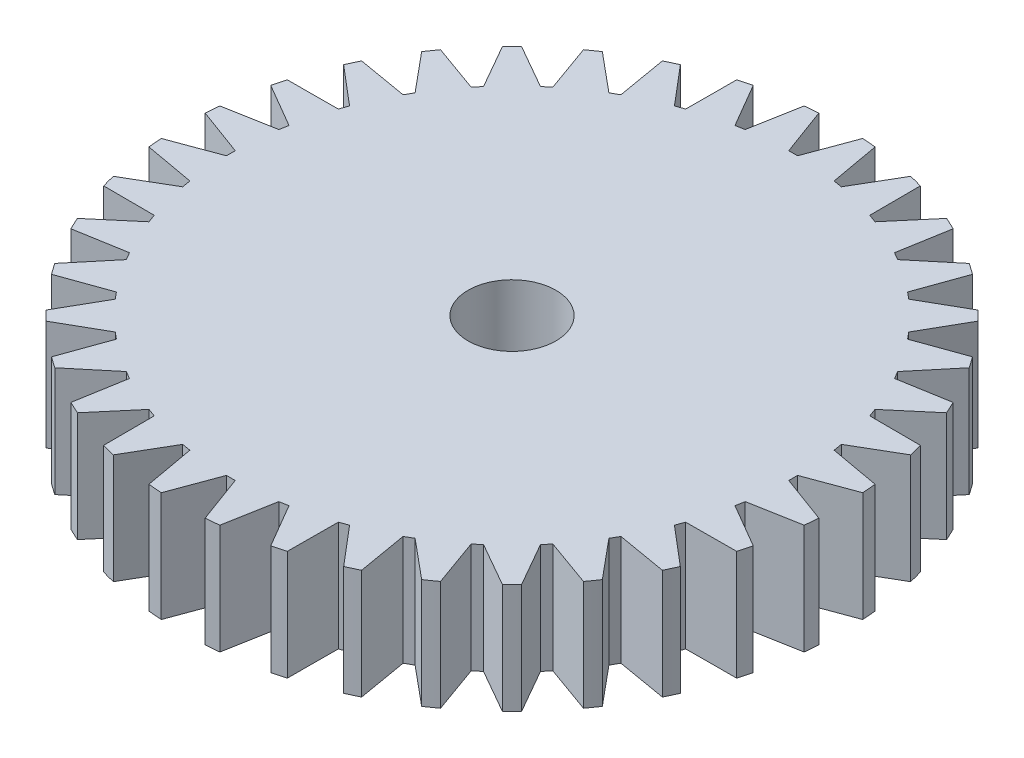
from build123d import *

# Parameters (mm, degrees)
SKETCH1_R           = 15
BOSS_EXTRUDE1_DEPTH = 5
SKETCH2_R           = 2
CUT_EXTRUDE1_DEPTH  = 6
CUT_EXTRUDE2_DEPTH  = 10
CIRPATTERN1_COUNT   = 36


with BuildPart() as part:
    # Sketch1 → Boss-Extrude1 (new body)
    with BuildSketch(Plane(origin=(0, 0, 0), x_dir=(1, 0, 0), z_dir=(0, 1, 0))):
        Circle(SKETCH1_R)
    extrude(amount=BOSS_EXTRUDE1_DEPTH)

    # Sketch2 → Cut-Extrude1 (cut, through all)
    with BuildSketch(Plane(origin=(0, 5, 0), x_dir=(1, 0, 0), z_dir=(0, 1, 0))):
        Circle(SKETCH2_R)
    extrude(amount=-CUT_EXTRUDE1_DEPTH, mode=Mode.SUBTRACT)

    # Sketch3 → Cut-Extrude2 (cut)
    with BuildSketch(Plane(origin=(0, 5, 0), x_dir=(1, 0, 0), z_dir=(0, 1, 0))):
        Polygon((0, 12.8), (0.2, 12.8), (1, 14.966629547), (1, 18.114701451), (-1, 18.114701451), (-1, 14.966629547), (-0.2, 12.8), align=None)
    cut_extrude2 = extrude(amount=-CUT_EXTRUDE2_DEPTH, mode=Mode.SUBTRACT)

    # CirPattern1: Cut-Extrude2 ×36 about axis
    cirpattern1_axis = Axis((0, 0, 0), (0, 1, 0))
    for i in range(1, CIRPATTERN1_COUNT):
        add(cut_extrude2.rotate(cirpattern1_axis, i * 360 / CIRPATTERN1_COUNT), mode=Mode.SUBTRACT)


solid = part.part
